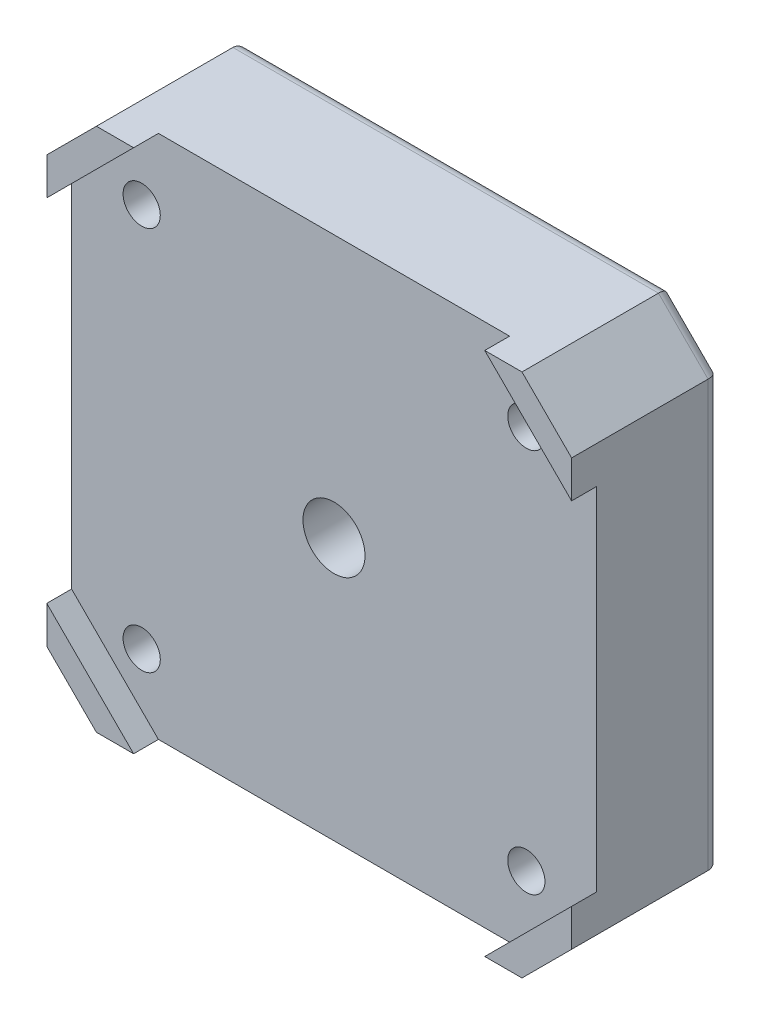
from build123d import *

# Parameters (mm, degrees)
Y_KSEKLIK_EKSTR_ZYON1_DEPTH = 12
KES_EKSTR_ZYON1_DEPTH       = 2
IZIM3_R                     = 1.5
KES_EKSTR_ZYON2_DEPTH       = 11
IZIM5_R                     = 3.1
KES_EKSTR_ZYON3_DEPTH       = 3
RADYUS1_R                   = 0.5
RADYUS2_R                   = 1
IZIM6_R                     = 5.5
KES_EKSTR_ZYON4_DEPTH       = 5
IZIM7_R                     = 2.5
KES_EKSTR_ZYON5_DEPTH       = 8
RADYUS3_R                   = 1


with BuildPart() as part:
    # Çizim1 → Yükseklik-Ekstrüzyon1 (new body)
    with BuildSketch(Plane.XY):
        Polygon((0, 38.3), (4, 42.3), (38.3, 42.3), (42.3, 38.3), (42.3, 4), (38.3, 0), (4, 0), (0, 4), align=None)
    extrude(amount=Y_KSEKLIK_EKSTR_ZYON1_DEPTH)

    # Çizim2 → Kes-Ekstrüzyon1 (cut)
    with BuildSketch(Plane.XY.offset(12)):
        Polygon((0, 35.3), (7, 42.3), (35.3, 42.3), (42.3, 35.3), (42.3, 7), (35.3, 0), (7, 0), (0, 7), align=None)
    extrude(amount=-KES_EKSTR_ZYON1_DEPTH, mode=Mode.SUBTRACT)

    # Çizim3 → Kes-Ekstrüzyon2 (cut, through all)
    with BuildSketch(Plane.XY.offset(10)):
        with Locations((5.65, 36.65)):
            Circle(IZIM3_R)
        with Locations((36.65, 36.65)):
            Circle(IZIM3_R)
        with Locations((36.65, 5.65)):
            Circle(IZIM3_R)
        with Locations((5.65, 5.65)):
            Circle(IZIM3_R)
    extrude(amount=-KES_EKSTR_ZYON2_DEPTH, mode=Mode.SUBTRACT)

    # Çizim5 → Kes-Ekstrüzyon3 (cut)
    with BuildSketch(Plane(origin=(0, 0, 0), x_dir=(-1, 0, 0), z_dir=(0, 0, -1))):
        with Locations((-36.65, 36.65)):
            Circle(IZIM5_R)
        with Locations((-5.65, 36.65)):
            Circle(IZIM5_R)
        with Locations((-5.65, 5.65)):
            Circle(IZIM5_R)
        with Locations((-36.65, 5.65)):
            Circle(IZIM5_R)
    extrude(amount=-KES_EKSTR_ZYON3_DEPTH, mode=Mode.SUBTRACT)

    # Radyus1
    radyus1_edges = [part.edges().sort_by_distance(p)[0] for p in [
        (39.75, 5.65, 0),
        (8.75, 5.65, 0),
        (8.75, 36.65, 0),
        (39.75, 36.65, 0),
    ]]
    fillet(radyus1_edges, radius=RADYUS1_R)

    # Radyus2
    radyus2_edges = [part.edges().sort_by_distance(p)[0] for p in [
        (2, 40.3, 0),
        (21.15, 42.3, 0),
        (40.3, 40.3, 0),
        (42.3, 21.15, 0),
        (40.3, 2, 0),
        (21.15, 0, 0),
        (2, 2, 0),
        (0, 21.15, 0),
    ]]
    fillet(radyus2_edges, radius=RADYUS2_R)

    # Çizim6 → Kes-Ekstrüzyon4 (cut)
    with BuildSketch(Plane(origin=(0, 0, 0), x_dir=(-1, 0, 0), z_dir=(0, 0, -1))):
        with Locations((-21.15, 21.15)):
            Circle(IZIM6_R)
    extrude(amount=-KES_EKSTR_ZYON4_DEPTH, mode=Mode.SUBTRACT)

    # Çizim7 → Kes-Ekstrüzyon5 (cut, through all)
    with BuildSketch(Plane(origin=(0, 0, 5), x_dir=(-1, 0, 0), z_dir=(0, 0, -1))):
        with Locations((-21.15, 21.15)):
            Circle(IZIM7_R)
    extrude(amount=-KES_EKSTR_ZYON5_DEPTH, mode=Mode.SUBTRACT)

    # Radyus3
    radyus3_edges = [part.edges().sort_by_distance(p)[0] for p in [
        (26.65, 21.15, 5),
        (26.65, 21.15, 0),
    ]]
    fillet(radyus3_edges, radius=RADYUS3_R)


solid = part.part
